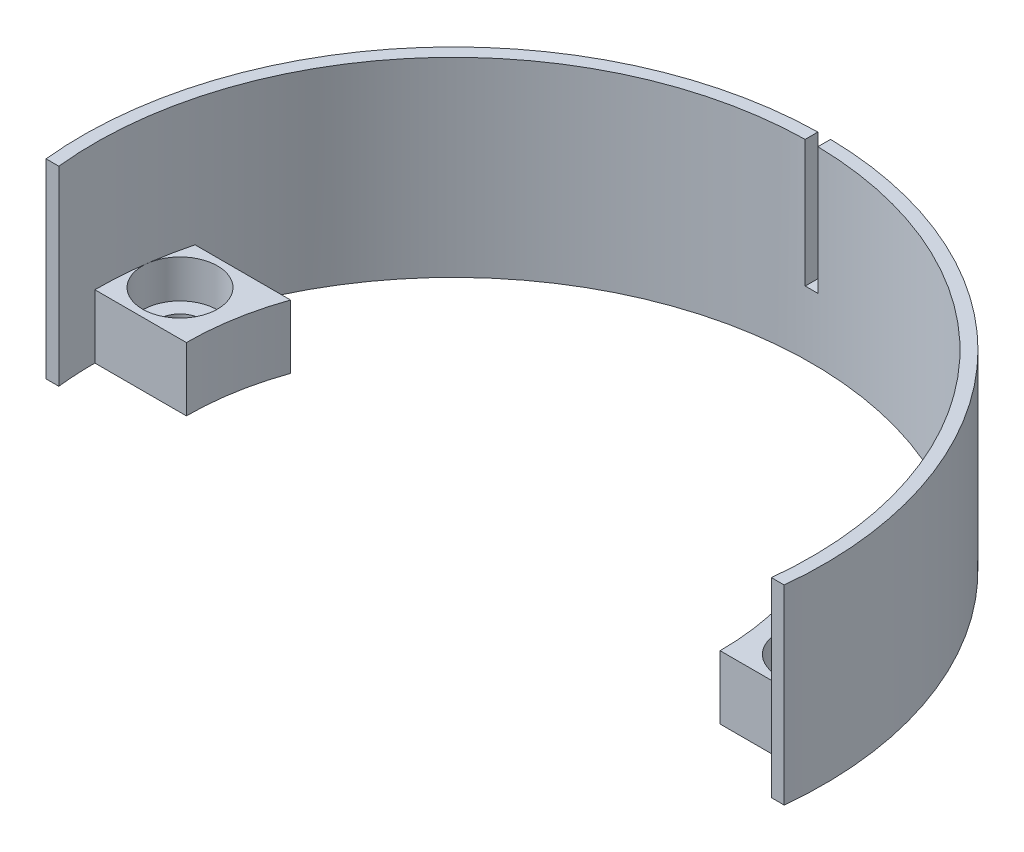
from build123d import *

# Parameters (mm, degrees)
CROQUIS1_R              = 1.7
SALIENTE_EXTRUIR1_DEPTH = 5
SALIENTE_EXTRUIR2_DEPTH = 10
CROQUIS3_R              = 2.95
CORTAR_EXTRUIR1_DEPTH   = 3


with BuildPart() as part:
    # Croquis1 → Saliente-Extruir1 (new body)
    with BuildSketch(Plane(origin=(0, 0, 0), x_dir=(1, 0, 0), z_dir=(0, 1, 0))):
        with BuildLine():
            Line((-29.045481576, -3), (-28.039971469, -3))
            ThreePointArc((-28.039971469, -3), (-28.159964448, -1.502132578), (-28.2, 0))
            Line((-28.2, 0), (-21, 0))
            ThreePointArc((-21, 0), (-20.697569753, 3.551141553), (-19.798989873, 7))
            Line((-19.798989873, 7), (-27.317393726, 7))
            ThreePointArc((-27.317393726, 7), (0, 28.2), (27.317393726, 7))
            Line((27.317393726, 7), (19.798989873, 7))
            ThreePointArc((19.798989873, 7), (20.697569753, 3.551141553), (21, 0))
            Line((21, 0), (28.2, 0))
            ThreePointArc((28.2, 0), (28.159964448, -1.502132578), (28.039971469, -3))
            Line((28.039971469, -3), (29.045481576, -3))
            ThreePointArc((29.045481576, -3), (0, 29.2), (-29.045481576, -3))
        make_face()
        with Locations((-25, 3.5)):
            Circle(CROQUIS1_R, mode=Mode.SUBTRACT)
        with Locations((25, 3.5)):
            Circle(CROQUIS1_R, mode=Mode.SUBTRACT)
    extrude(amount=SALIENTE_EXTRUIR1_DEPTH)

    # Croquis2 → Saliente-Extruir2 (add)
    with BuildSketch(Plane(origin=(0, 5, 0), x_dir=(1, 0, 0), z_dir=(0, 1, 0))):
        with BuildLine():
            Line((28.039971469, -3), (29.045481576, -3))
            ThreePointArc((29.045481576, -3), (21.848911842, 19.371759118), (0.5, 29.195718864))
            Line((0.5, 29.195718864), (0.5, 28.195567027))
            ThreePointArc((0.5, 28.195567027), (21.140561568, 18.663243464), (28.039971469, -3))
        make_face()
        with BuildLine():
            Line((-29.045481576, -3), (-28.039971469, -3))
            ThreePointArc((-28.039971469, -3), (-21.140561568, 18.663243464), (-0.5, 28.195567027))
            Line((-0.5, 28.195567027), (-0.5, 29.195718864))
            ThreePointArc((-0.5, 29.195718864), (-21.848911842, 19.371759118), (-29.045481576, -3))
        make_face()
    extrude(amount=SALIENTE_EXTRUIR2_DEPTH)

    # Croquis3 → Cortar-Extruir1 (cut)
    with BuildSketch(Plane(origin=(0, 5, 0), x_dir=(1, 0, 0), z_dir=(0, 1, 0))):
        with Locations((-25, 3.5)):
            Circle(CROQUIS3_R)
        with Locations((25, 3.5)):
            Circle(CROQUIS3_R)
    extrude(amount=-CORTAR_EXTRUIR1_DEPTH, mode=Mode.SUBTRACT)


solid = part.part
